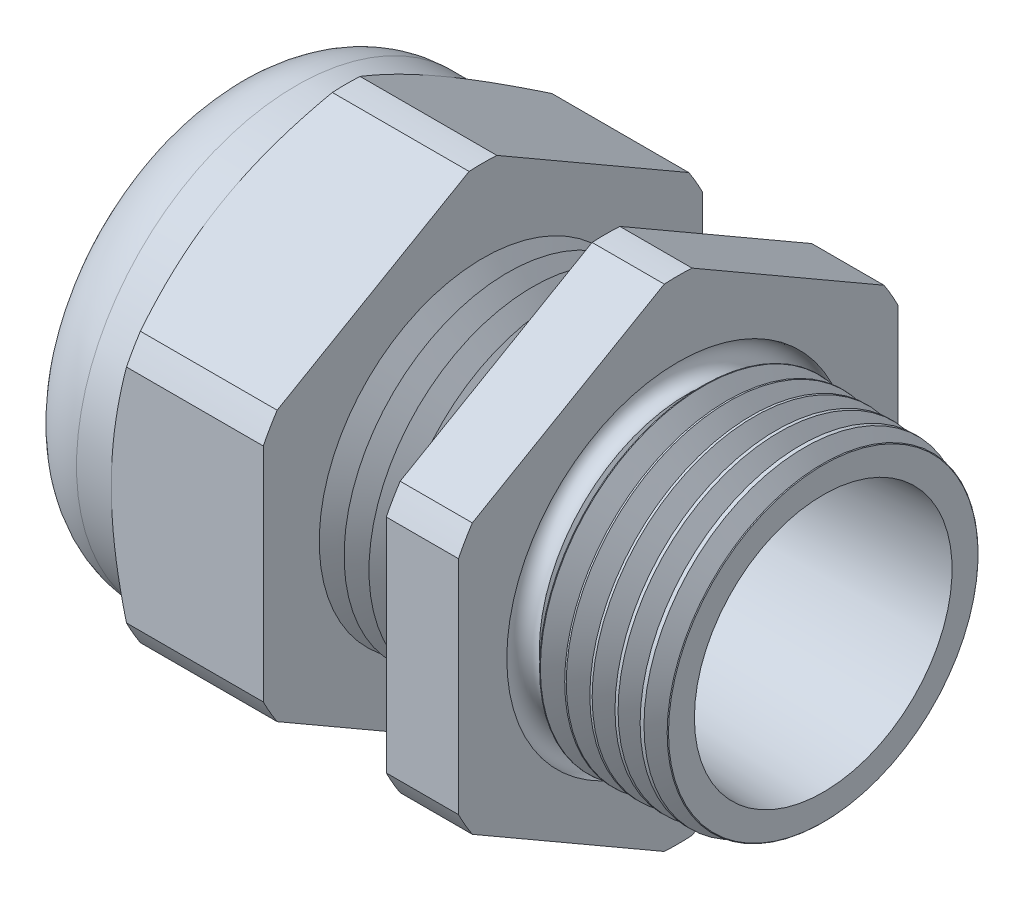
from build123d import *

# Parameters (mm, degrees)
SKETCH2_OUTSIDE_W  = 43.424
SKETCH2_OUTSIDE_H  = 43.424
CUT_EXTRUDE1_DEPTH = 21.2725
CHAMFER1_SIZE      = 0.326149358
CHAMFER1_SIZE2     = 0.3175
SKETCH3_OUTSIDE_W  = 147.812
SKETCH3_OUTSIDE_H  = 151.042
SKETCH3_OUTSIDE_R  = 13.462
CUT_EXTRUDE2_DEPTH = 31.1625
CUT_EXTRUDE2_DRAFT = -60
SKETCH14_W         = 6.6675
SKETCH14_H         = 3.429
FILLET1_R          = 4.53644
LPATTERN1_COUNT    = 5
LPATTERN1_PITCH    = 1.524
LPATTERN2_COUNT    = 6
LPATTERN2_PITCH    = 1.524
SKETCH15_R         = 0.8255


with BuildPart() as part:
    # Sketch1 → Revolve1 (revolve)
    with BuildSketch(Plane.XY, mode=Mode.PRIVATE) as revolve1_sk:
        Polygon((-11.959166667, 10.033), (-11.959166667, 15.07744), (-21.2725, 15.07744), (-21.2725, 10.033), (-27.94, 10.033), (-27.94, 8.52805), (-21.2725, 8.52805), (-21.2725, 6.985), (-11.959166667, 6.985), (8.89, 7.895294276), (8.89, 9.800207157), (0, 10.033), (0, 15.07744), (-4.422885572, 15.07744), (-4.422885572, 10.033), align=None)
    revolve(revolve1_sk.sketch.rotate(Axis((-18.386021217, 0, 0), (1, 0, 0)), 90), axis=Axis((-18.386021217, 0, 0), (1, 0, 0)))  # turned: the seam where the file's is

    # Sketch2 outside → Cut-Extrude1 (cut)
    with BuildSketch(Plane(origin=(0, 0, 0), x_dir=(0, 0, -1), z_dir=(1, 0, 0))):
        Rectangle(SKETCH2_OUTSIDE_W, SKETCH2_OUTSIDE_H)
        with BuildLine():
            Line((13.462, -6.789974444), (13.462, 6.789974444))
            ThreePointArc((13.462, 6.789974444), (13.057446064, 7.53872), (12.61129036, 8.263446764))
            Line((12.61129036, 8.263446764), (0.85070964, 15.053421208))
            ThreePointArc((0.85070964, 15.053421208), (0, 15.07744), (-0.85070964, 15.053421208))
            Line((-0.85070964, 15.053421208), (-12.61129036, 8.263446764))
            ThreePointArc((-12.61129036, 8.263446764), (-13.057446064, 7.53872), (-13.462, 6.789974444))
            Line((-13.462, 6.789974444), (-13.462, -6.789974444))
            ThreePointArc((-13.462, -6.789974444), (-13.057446064, -7.53872), (-12.61129036, -8.263446764))
            Line((-12.61129036, -8.263446764), (-0.85070964, -15.053421208))
            ThreePointArc((-0.85070964, -15.053421208), (0, -15.07744), (0.85070964, -15.053421208))
            Line((0.85070964, -15.053421208), (12.61129036, -8.263446764))
            ThreePointArc((12.61129036, -8.263446764), (13.057446064, -7.53872), (13.462, -6.789974444))
        make_face(mode=Mode.SUBTRACT)
    extrude(amount=-CUT_EXTRUDE1_DEPTH, mode=Mode.SUBTRACT)

    # Chamfer1
    chamfer1_edges = [part.edges().sort_by_distance(p)[0] for p in [
        (8.89, 0, -9.800207157),
    ]]
    chamfer1_side = [part.faces().sort_by_distance(p)[0] for p in [
        (4.445, 0, -9.916603579),
    ]]
    chamfer(chamfer1_edges, length=CHAMFER1_SIZE, length2=CHAMFER1_SIZE2, reference=chamfer1_side[0])


with BuildPart() as cut_extrude2_tool:
    # Sketch3 outside → Cut-Extrude2 (with draft: the straight prism first)
    with BuildSketch(Plane.ZY.offset(21.2725)):
        Rectangle(SKETCH3_OUTSIDE_W, SKETCH3_OUTSIDE_H)
        Circle(SKETCH3_OUTSIDE_R, mode=Mode.SUBTRACT)
    extrude(amount=-CUT_EXTRUDE2_DEPTH)
    # Cut-Extrude2: the draft: its side faces are tilted about the plane it starts from
    cut_extrude2_sides = [cut_extrude2_tool.faces().sort_by_distance(p)[0] for p in [
        (-5.69125, -75.521, 0),
        (-5.69125, 0, 73.906),
        (-5.69125, 75.521, 0),
        (-5.69125, 0, -73.906),
        (-5.69125, 0, -13.462),
    ]]
    draft(cut_extrude2_sides, Plane.ZY.offset(21.2725), CUT_EXTRUDE2_DRAFT)


with BuildPart() as part_1:
    add(part.part)

    # Cut-Extrude2: cut by cut_extrude2_tool
    add(cut_extrude2_tool.part, mode=Mode.SUBTRACT)

    # Sketch14 → Revolve4 (revolve)
    with BuildSketch(Plane.XY, mode=Mode.PRIVATE) as revolve4_sk:
        with Locations((-24.60625, 11.7475)):
            Rectangle(SKETCH14_W, SKETCH14_H)
    revolve(revolve4_sk.sketch.rotate(Axis((-18.386021217, 0, 0), (1, 0, 0)), 90), axis=Axis((-18.386021217, 0, 0), (1, 0, 0)))  # turned: the seam where the file's is

    # Fillet1
    fillet1_edges = [part_1.edges().sort_by_distance(p)[0] for p in [
        (-27.94, 0, -13.462),
    ]]
    fillet(fillet1_edges, radius=FILLET1_R)

    # Sketch10 → Cut-Revolve1 (revolve, cut)
    with BuildSketch(Plane.XY, mode=Mode.PRIVATE) as cut_revolve1_sk:
        Polygon((-11.959166667, 10.033), (-11.197167022, 8.7131779), (-10.435167377, 10.033), align=None)
    cut_revolve1 = revolve(cut_revolve1_sk.sketch.rotate(Axis((15.58962545, 0, 0), (-1, 0, 0)), 90), axis=Axis((15.58962545, 0, 0), (-1, 0, 0)), mode=Mode.SUBTRACT)  # turned: the seam where the file's is

    # LPattern1: Cut-Revolve1 ×5
    with Locations(*[(i * LPATTERN1_PITCH, 0, 0) for i in range(1, LPATTERN1_COUNT)]):
        add(cut_revolve1, mode=Mode.SUBTRACT)

    # Sketch13 → Cut-Revolve2 (revolve, cut)
    with BuildSketch(Plane.XY, mode=Mode.PRIVATE) as cut_revolve2_sk:
        Polygon((0, 10.033), (1.523999289, 10.033), (0.761999645, 8.7131779), align=None)
    cut_revolve2 = revolve(cut_revolve2_sk.sketch.rotate(Axis((-18.386021217, 0, 0), (1, 0, 0)), 270), axis=Axis((-18.386021217, 0, 0), (1, 0, 0)), mode=Mode.SUBTRACT)  # turned: the seam where the file's is

    # LPattern2: Cut-Revolve2 ×6
    with Locations(*[(i * LPATTERN2_PITCH, 0, 0) for i in range(1, LPATTERN2_COUNT)]):
        add(cut_revolve2, mode=Mode.SUBTRACT)

    # Sketch15 → Cut-Revolve3 (revolve, cut)
    with BuildSketch(Plane.XY, mode=Mode.PRIVATE) as cut_revolve3_sk:
        with Locations((0, -9.673698712)):
            Circle(SKETCH15_R)
    revolve(cut_revolve3_sk.sketch.rotate(Axis((1.524, 0, 0), (-1, 0, 0)), 90), axis=Axis((1.524, 0, 0), (-1, 0, 0)), mode=Mode.SUBTRACT)  # turned: the seam where the file's is


with BuildPart() as body_2:
    # Sketch9 → Revolve3 (revolve)
    with BuildSketch(Plane.XY, mode=Mode.PRIVATE) as revolve3_sk:
        with BuildLine():
            Line((-27.178, 6.985), (-27.178, 8.27405))
            ThreePointArc((-27.178, 8.27405), (-27.103605122, 8.453655122), (-26.924, 8.52805))
            Line((-26.924, 8.52805), (-21.2725, 8.52805))
            Line((-21.2725, 8.52805), (-21.2725, 6.985))
            Line((-21.2725, 6.985), (-27.178, 6.985))
        make_face()
    revolve(revolve3_sk.sketch.rotate(Axis((8.695207459, 0, 0), (-1, 0, 0)), 270), axis=Axis((8.695207459, 0, 0), (-1, 0, 0)))  # turned: the seam where the file's is


solid = Compound([part_1.part, body_2.part])
